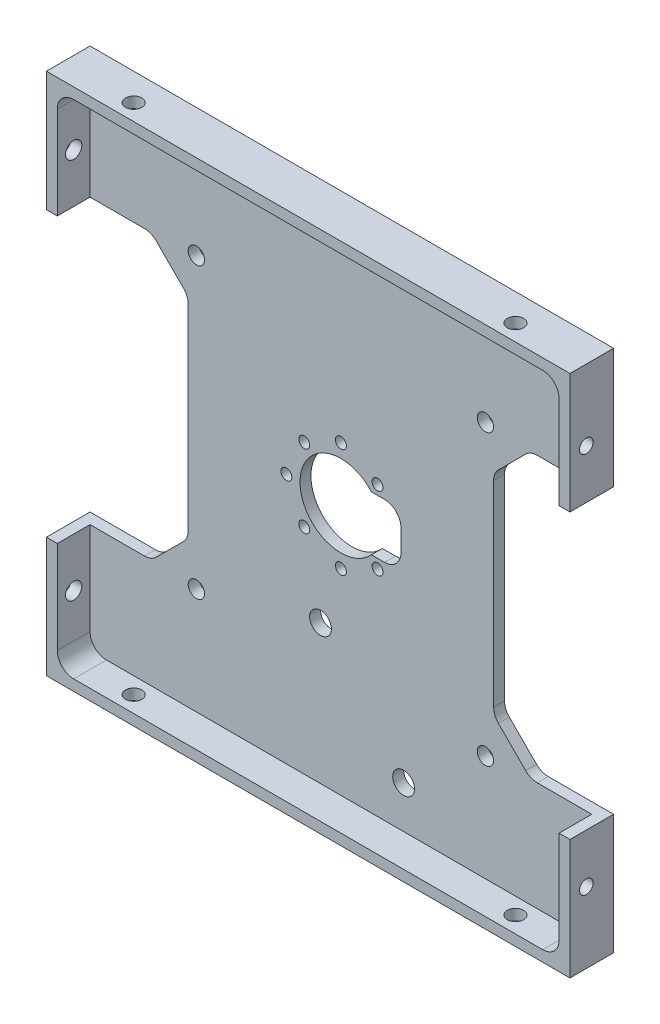
from build123d import *

# Parameters (mm, degrees)
SKETCH1_W                 = 96
SKETCH1_H                 = 96
BOSS_EXTRUDE1_DEPTH       = 8
SKETCH2_W                 = 92
SKETCH2_H                 = 92
COMPONENT_PLATFORM_DEPTH  = 6
CABLE_SLOTS_DEPTH         = 6
SKETCH4_R                 = 7.5
CENTER_MASS_CUT_DEPTH     = 6
INNER_CORNER_FILLETS_R    = 3
SKETCH10_W                = 11
SKETCH10_H                = 10
MOTOR_CUTOUT_DEPTH        = 2
FILLET1_R                 = 3
M3X0_5_TAPPED_HOLE1_D     = 2.5
M3X0_5_TAPPED_HOLE1_DEPTH = 2
F_3_0MM_DOWEL_HOLE1_D     = 3
F_3_0MM_DOWEL_HOLE1_DEPTH = 2
F_3_0MM_DOWEL_HOLE2_D     = 3
F_3_0MM_DOWEL_HOLE2_DEPTH = 2
F_2_0MM_DOWEL_HOLE1_D     = 2
F_2_0MM_DOWEL_HOLE1_DEPTH = 2
F_4_0MM_DOWEL_HOLE1_D     = 4
F_4_0MM_DOWEL_HOLE1_DEPTH = 2
F_3_0MM_DOWEL_HOLE3_D     = 3
F_3_0MM_DOWEL_HOLE3_DEPTH = 2


with BuildPart() as part:
    # Sketch1 → Boss-Extrude1 (new body)
    with BuildSketch(Plane.XY):
        Rectangle(SKETCH1_W, SKETCH1_H)
    extrude(amount=BOSS_EXTRUDE1_DEPTH)

    # Sketch2 → Component Platform (cut)
    with BuildSketch(Plane.XY.offset(8)):
        Rectangle(SKETCH2_W, SKETCH2_H)
    extrude(amount=-COMPONENT_PLATFORM_DEPTH, mode=Mode.SUBTRACT)

    # Sketch3 → Cable Slots (cut, symmetric)
    with BuildSketch(Plane.XY.offset(2)):
        with BuildLine():
            Line((-33.878679656, -25.121320344), (-28.878679656, -20.121320344))
            ThreePointArc((-28.878679656, -20.121320344), (-28.228361402, -19.148050297), (-28, -18))
            Line((-28, -18), (-28, 18))
            ThreePointArc((-28, 18), (-28.228361402, 19.148050297), (-28.878679656, 20.121320344))
            Line((-28.878679656, 20.121320344), (-33.878679656, 25.121320344))
            ThreePointArc((-33.878679656, 25.121320344), (-34.851949703, 25.771638598), (-36, 26))
            Line((-36, 26), (-48, 26))
            Line((-48, 26), (-48, -26))
            Line((-48, -26), (-36, -26))
            ThreePointArc((-36, -26), (-34.851949703, -25.771638598), (-33.878679656, -25.121320344))
        make_face()
        with BuildLine():
            Line((48, -26), (48, 26))
            Line((48, 26), (36, 26))
            ThreePointArc((36, 26), (34.851949703, 25.771638598), (33.878679656, 25.121320344))
            Line((33.878679656, 25.121320344), (28.878679656, 20.121320344))
            ThreePointArc((28.878679656, 20.121320344), (28.228361402, 19.148050297), (28, 18))
            Line((28, 18), (28, -18))
            ThreePointArc((28, -18), (28.228361402, -19.148050297), (28.878679656, -20.121320344))
            Line((28.878679656, -20.121320344), (33.878679656, -25.121320344))
            ThreePointArc((33.878679656, -25.121320344), (34.851949703, -25.771638598), (36, -26))
            Line((36, -26), (48, -26))
        make_face()
    extrude(amount=CABLE_SLOTS_DEPTH, both=True, mode=Mode.SUBTRACT)

    # Sketch4 → Center Mass Cut (cut)
    with BuildSketch(Plane.XY.offset(2)):
        Circle(SKETCH4_R)
    extrude(amount=-CENTER_MASS_CUT_DEPTH, mode=Mode.SUBTRACT)

    # Inner Corner Fillets
    inner_corner_fillets_edges = [part.edges().sort_by_distance(p)[0] for p in [
        (-46, -46, 5),
        (-46, 46, 5),
        (46, 46, 5),
        (46, -46, 5),
    ]]
    fillet(inner_corner_fillets_edges, radius=INNER_CORNER_FILLETS_R)

    # Sketch10 → Motor Cutout (cut)
    with BuildSketch(Plane.XY.offset(2)):
        with Locations((5.5, 0)):
            Rectangle(SKETCH10_W, SKETCH10_H)
    extrude(amount=-MOTOR_CUTOUT_DEPTH, mode=Mode.SUBTRACT)

    # Fillet1
    fillet1_edges = [part.edges().sort_by_distance(p)[0] for p in [
        (11, -5, 1),
        (11, 5, 1),
    ]]
    fillet(fillet1_edges, radius=FILLET1_R)

    # M3x0.5 Tapped Hole1
    with Locations(Plane(origin=(48, 0, 0), x_dir=(0, 0, -1), z_dir=(1, 0, 0))):
        with Locations((-5, -35), (-5, 35)):
            Hole(M3X0_5_TAPPED_HOLE1_D / 2, depth=M3X0_5_TAPPED_HOLE1_DEPTH)

    # Ø3.0mm Dowel Hole1
    with Locations(Plane(origin=(0, 48, 0), x_dir=(1, 0, 0), z_dir=(0, 1, 0))):
        with Locations((35, -5), (-35, -5)):
            f_3_0mm_dowel_hole1 = Hole(F_3_0MM_DOWEL_HOLE1_D / 2, depth=F_3_0MM_DOWEL_HOLE1_DEPTH)

    # Mirror2: Ø3.0mm Dowel Hole1 across plane
    add(f_3_0mm_dowel_hole1.mirror(Plane(origin=(0, 0, 0), x_dir=(0, 0, 1), z_dir=(0, -1, 0))), mode=Mode.SUBTRACT)

    # Ø3.0mm Dowel Hole2
    with Locations(Plane.XY.offset(2)):
        with Locations((-26.5, -26.5), (26.5, -26.5), (26.5, 26.5), (-26.5, 26.5)):
            Hole(F_3_0MM_DOWEL_HOLE2_D / 2, depth=F_3_0MM_DOWEL_HOLE2_DEPTH)

    # Ø2.0mm Dowel Hole1
    with Locations(Plane.XY.offset(2)):
        with Locations((6.72, -6.72), (0, -10), (-6.72, -6.72), (-10, 0), (-6.72, 6.72), (0, 10), (6.72, 6.72)):
            Hole(F_2_0MM_DOWEL_HOLE1_D / 2, depth=F_2_0MM_DOWEL_HOLE1_DEPTH)

    # Ø4.0mm Dowel Hole1
    with Locations(Plane.XY.offset(2)):
        with Locations((-3.74, -20.47), (11.5, -38.25)):
            Hole(F_4_0MM_DOWEL_HOLE1_D / 2, depth=F_4_0MM_DOWEL_HOLE1_DEPTH)

    # Ø3.0mm Dowel Hole3
    with Locations(Plane(origin=(-48, 35, 5), x_dir=(0, 0, -1), z_dir=(-1, 0, 0))):
        with Locations((0, 0), (0, 70)):
            Hole(F_3_0MM_DOWEL_HOLE3_D / 2, depth=F_3_0MM_DOWEL_HOLE3_DEPTH)


solid = part.part
